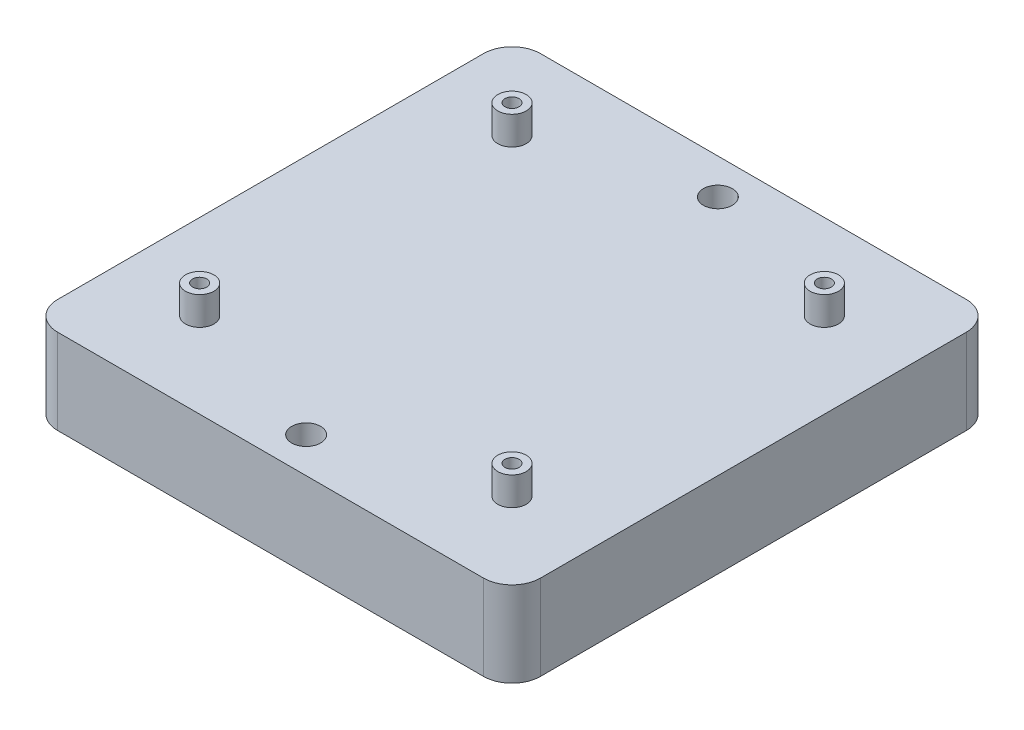
from build123d import *

# Parameters (mm, degrees)
SKETCH1_W           = 170
SKETCH1_H           = 170
BOSS_EXTRUDE2_DEPTH = 30
SKETCH2_R           = 5.1
CUT_EXTRUDE1_DEPTH  = 25
SKETCH3_R           = 5
SKETCH3_R_2         = 2.5
BOSS_EXTRUDE3_DEPTH = 10
FILLET1_R           = 10


with BuildPart() as part:
    # Sketch1 → Boss-Extrude2 (new body)
    with BuildSketch(Plane(origin=(0, 0, 0), x_dir=(1, 0, 0), z_dir=(0, 1, 0))):
        with Locations((85, 85)):
            Rectangle(SKETCH1_W, SKETCH1_H)
    extrude(amount=BOSS_EXTRUDE2_DEPTH)

    # Sketch2 → Cut-Extrude1 (cut)
    with BuildSketch(Plane(origin=(0, 30, 0), x_dir=(1, 0, 0), z_dir=(0, 1, 0))):
        with Locations((85, 12.5)):
            Circle(SKETCH2_R)
        with Locations((85, 157.5)):
            Circle(SKETCH2_R)
    extrude(amount=-CUT_EXTRUDE1_DEPTH, mode=Mode.SUBTRACT)

    # Sketch3 → Boss-Extrude3 (add)
    with BuildSketch(Plane(origin=(0, 30, 0), x_dir=(1, 0, 0), z_dir=(0, 1, 0))):
        with Locations((30, 30)):
            Circle(SKETCH3_R)
        with Locations((30, 30)):
            Circle(SKETCH3_R_2, mode=Mode.SUBTRACT)
        with Locations((140, 30)):
            Circle(SKETCH3_R)
        with Locations((140, 30)):
            Circle(SKETCH3_R_2, mode=Mode.SUBTRACT)
        with Locations((30, 140)):
            Circle(SKETCH3_R)
        with Locations((30, 140)):
            Circle(SKETCH3_R_2, mode=Mode.SUBTRACT)
        with Locations((140, 140)):
            Circle(SKETCH3_R)
        with Locations((140, 140)):
            Circle(SKETCH3_R_2, mode=Mode.SUBTRACT)
    extrude(amount=BOSS_EXTRUDE3_DEPTH)

    # Fillet1
    fillet1_edges = [part.edges().sort_by_distance(p)[0] for p in [
        (0, 15, -170),
        (170, 15, -170),
        (170, 15, 0),
        (0, 15, 0),
    ]]
    fillet(fillet1_edges, radius=FILLET1_R)


solid = part.part
